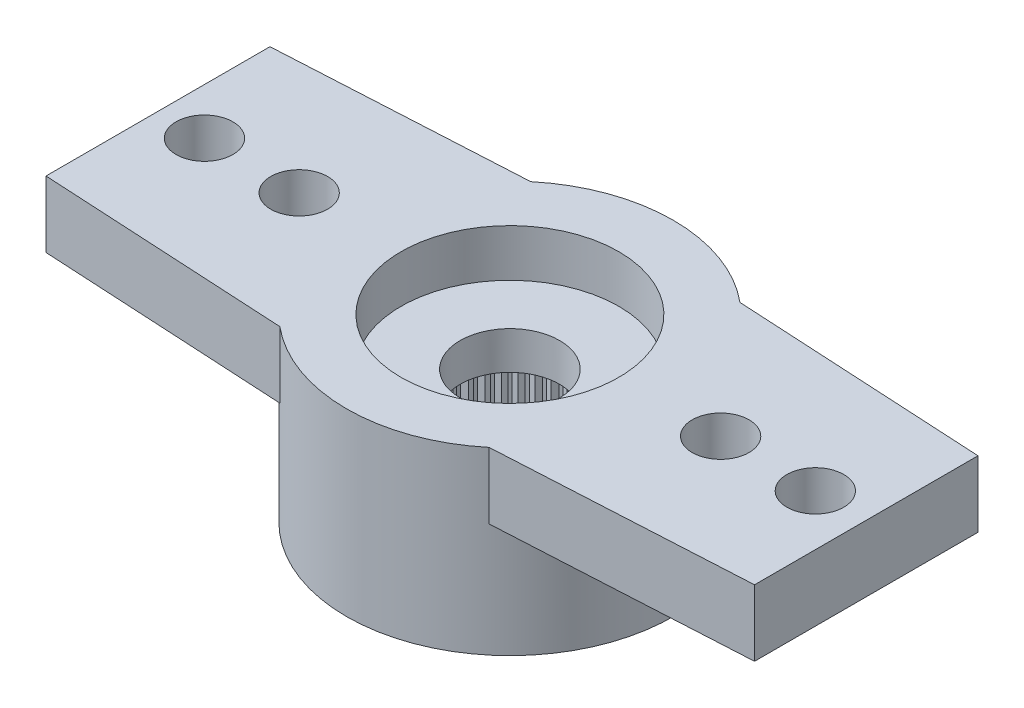
from build123d import *

# Parameters (mm, degrees)
RESSALTO_EXTRUS_O1_DEPTH = 1.4
ESBO_O2_R                = 3.45
RESSALTO_EXTRUS_O2_DEPTH = 2.4
FURO4_D                  = 1.2
PADR_O_LINEAR1_COUNT     = 6
PADR_O_LINEAR1_PITCH     = 2
PADR_OCIRCULAR2_COUNT    = 2
PADR_OCIRCULAR2_COPY_1_D = 1.2
PADR_OCIRCULAR2_COPY_2_D = 1.2
PADR_OCIRCULAR2_COPY_3_D = 1.2
PADR_OCIRCULAR2_COPY_4_D = 1.2
PADR_OCIRCULAR2_COPY_5_D = 1.2
FURO1_D                  = 4.95
FURO1_DEPTH              = 2
FURO2_D                  = 4.6
FURO2_DEPTH              = 1
FURO3_D                  = 2.1
RESSALTO_EXTRUS_O3_DEPTH = 2
PADR_OCIRCULAR1_COUNT    = 60
SKETCH1_W                = 35.403696315
SKETCH1_H                = 11.972118771
SKETCH1_W_2              = 14.957609346
SKETCH1_H_2              = 8.112090552
CUT_EXTRUDE1_DEPTH       = 10


with BuildPart() as part:
    # Esboço1 → Ressalto-extrusão1 (new body)
    with BuildSketch(Plane(origin=(0, 0, 0), x_dir=(1, 0, 0), z_dir=(0, 1, 0))):
        with BuildLine():
            Line((-14.159121967, 1.99702088), (-2.209072203, 2.65))
            ThreePointArc((-2.209072203, 2.65), (3.45, 0), (-2.209072203, -2.65))
            Line((-2.209072203, -2.65), (-14.159121967, -1.99702088))
            ThreePointArc((-14.159121967, -1.99702088), (-16.05, 0), (-14.159121967, 1.99702088))
        make_face()
    ressalto_extrus_o1 = extrude(amount=-RESSALTO_EXTRUS_O1_DEPTH)

    # Esboço2 → Ressalto-extrusão2 (add)
    with BuildSketch(Plane.XZ.offset(1.4)):
        Circle(ESBO_O2_R)
    extrude(amount=RESSALTO_EXTRUS_O2_DEPTH)

    # Furo4 (through all)
    with Locations(Plane(origin=(0, 0, 0), x_dir=(1, 0, 0), z_dir=(0, 1, 0))):
        with Locations((-14.45, 0)):
            furo4 = Hole(FURO4_D / 2)

    # Padrão linear1: Furo4 ×6
    with Locations(*[(i * PADR_O_LINEAR1_PITCH, 0, 0) for i in range(1, PADR_O_LINEAR1_COUNT)]):
        add(furo4, mode=Mode.SUBTRACT)

    # PadrãoCircular2: Ressalto-extrusão1, Furo4 ×2 about axis
    padr_ocircular2_axis = Axis((0, 0, 0), (0, 1, 0))
    for i in range(1, PADR_OCIRCULAR2_COUNT):
        add(ressalto_extrus_o1.rotate(padr_ocircular2_axis, i * 360 / PADR_OCIRCULAR2_COUNT))
        add(furo4.rotate(padr_ocircular2_axis, i * 360 / PADR_OCIRCULAR2_COUNT), mode=Mode.SUBTRACT)

    # PadrãoCircular2 copy 1 (through all)
    with Locations(Plane(origin=(-2, 0, 0), x_dir=(-1, 0, 0), z_dir=(0, 1, 0))):
        with Locations((-14.45, 0)):
            Hole(PADR_OCIRCULAR2_COPY_1_D / 2)

    # PadrãoCircular2 copy 2 (through all)
    with Locations(Plane(origin=(-4, 0, 0), x_dir=(-1, 0, 0), z_dir=(0, 1, 0))):
        with Locations((-14.45, 0)):
            Hole(PADR_OCIRCULAR2_COPY_2_D / 2)

    # PadrãoCircular2 copy 3 (through all)
    with Locations(Plane(origin=(-6, 0, 0), x_dir=(-1, 0, 0), z_dir=(0, 1, 0))):
        with Locations((-14.45, 0)):
            Hole(PADR_OCIRCULAR2_COPY_3_D / 2)

    # PadrãoCircular2 copy 4 (through all)
    with Locations(Plane(origin=(-8, 0, 0), x_dir=(-1, 0, 0), z_dir=(0, 1, 0))):
        with Locations((-14.45, 0)):
            Hole(PADR_OCIRCULAR2_COPY_4_D / 2)

    # PadrãoCircular2 copy 5 (through all)
    with Locations(Plane(origin=(-10, 0, 0), x_dir=(-1, 0, 0), z_dir=(0, 1, 0))):
        with Locations((-14.45, 0)):
            Hole(PADR_OCIRCULAR2_COPY_5_D / 2)

    # Furo1
    with Locations(Plane(origin=(0, -3.8, 0), x_dir=(-1, 0, 0), z_dir=(0, -1, 0))):
        with Locations((0, 0)):
            Hole(FURO1_D / 2, depth=FURO1_DEPTH)

    # Furo2
    with Locations(Plane(origin=(0, 0, 0), x_dir=(1, 0, 0), z_dir=(0, 1, 0))):
        with Locations((0, 0)):
            Hole(FURO2_D / 2, depth=FURO2_DEPTH)

    # Furo3 (through all)
    with Locations(Plane(origin=(0, 0, 0), x_dir=(1, 0, 0), z_dir=(0, 1, 0))):
        with Locations((0, 0)):
            Hole(FURO3_D / 2)

    # Esboço11 → Ressalto-extrusão3 (add)
    with BuildSketch(Plane.XZ.offset(3.8)):
        with BuildLine():
            Line((-0.098056786, 2.473056786), (0, 2.375))
            Line((0, 2.375), (0.098056786, 2.473056786))
            ThreePointArc((0.098056786, 2.473056786), (0, 2.475), (-0.098056786, 2.473056786))
        make_face()
    ressalto_extrus_o3 = extrude(amount=-RESSALTO_EXTRUS_O3_DEPTH)

    # PadrãoCircular1: Ressalto-extrusão3 ×60 about axis
    padr_ocircular1_axis = Axis((0, 0, 0), (0, 1, 0))
    for i in range(1, PADR_OCIRCULAR1_COUNT):
        add(ressalto_extrus_o3.rotate(padr_ocircular1_axis, i * 360 / PADR_OCIRCULAR1_COUNT))

    # Sketch1 → Cut-Extrude1 (cut)
    with BuildSketch(Plane(origin=(0, 0, 0), x_dir=(1, 0, 0), z_dir=(0, 1, 0))):
        with Locations((0.52934345, 0.081075901)):
            Rectangle(SKETCH1_W, SKETCH1_H)
        with Locations((0.046839923, 0.050919431)):
            Rectangle(SKETCH1_W_2, SKETCH1_H_2, mode=Mode.SUBTRACT)
    extrude(amount=-CUT_EXTRUDE1_DEPTH, mode=Mode.SUBTRACT)


solid = part.part
